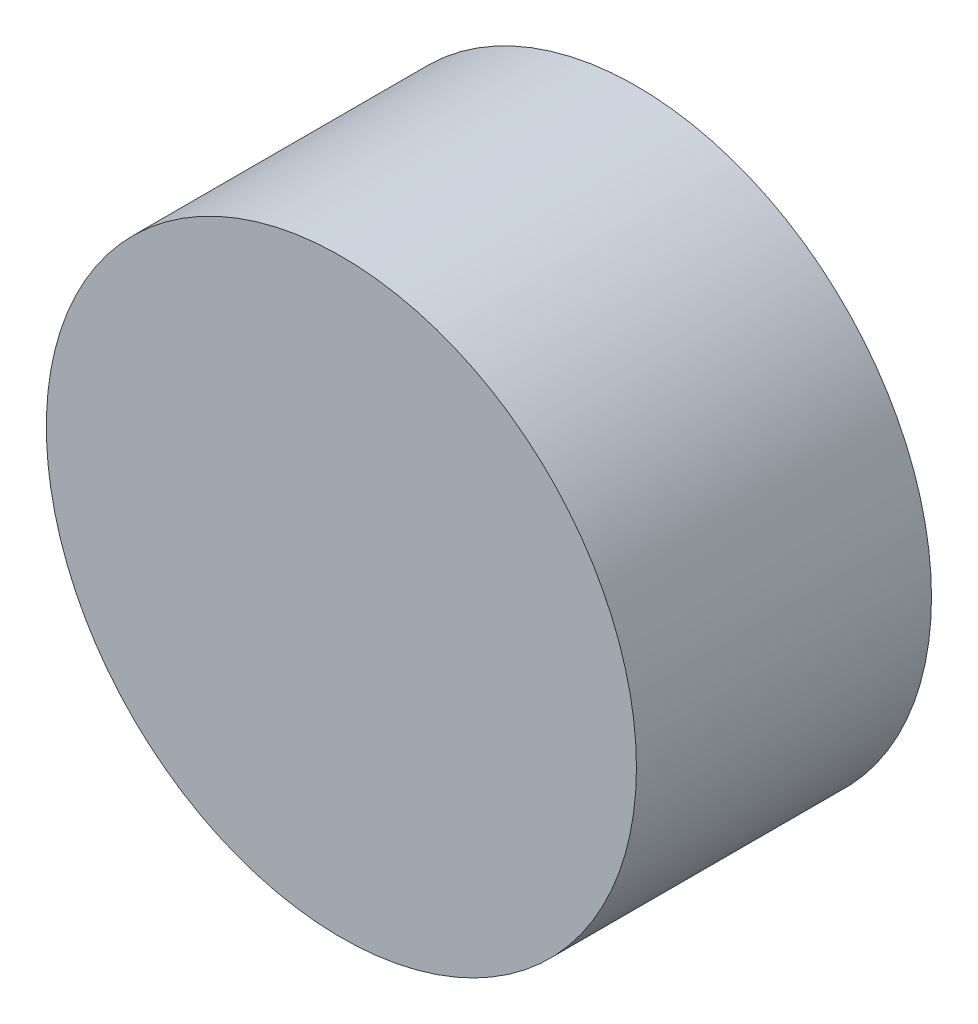
from build123d import *

# Parameters (mm, degrees)
SKETCH1_R           = 3
BOSS_EXTRUDE1_DEPTH = 3


with BuildPart() as part:
    # Sketch1 → Boss-Extrude1 (new body)
    with BuildSketch(Plane.XY):
        Circle(SKETCH1_R)
    extrude(amount=BOSS_EXTRUDE1_DEPTH)


solid = part.part
